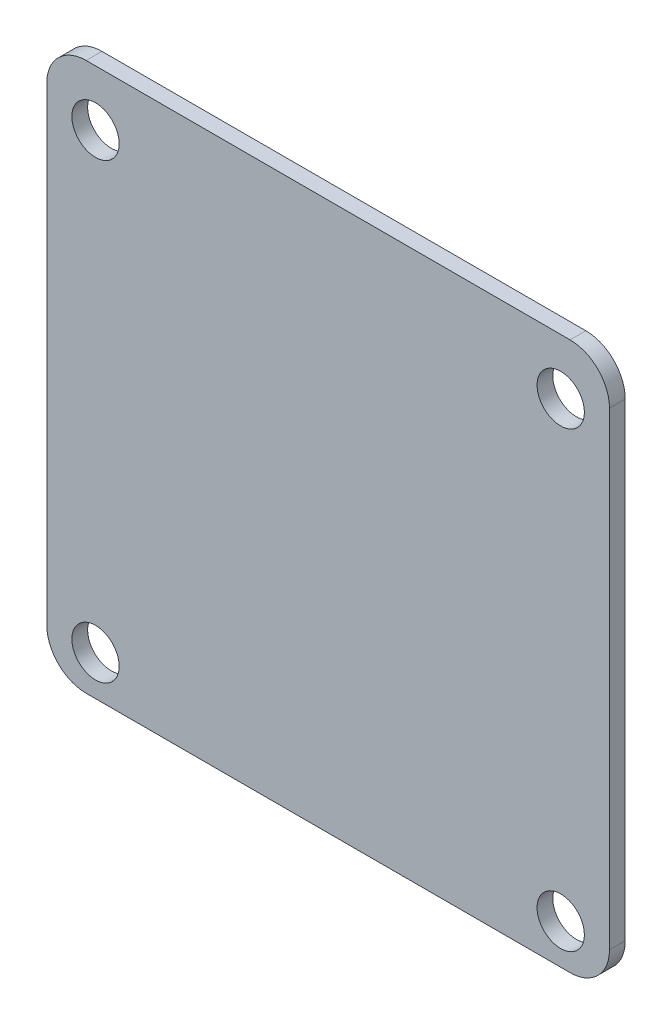
from build123d import *

# Parameters (mm, degrees)
ESQUISSE1_R        = 1.5
BOSS_EXTRU_1_DEPTH = 1


with BuildPart() as part:
    # Esquisse1 → Boss.-Extru.1 (new body)
    with BuildSketch(Plane.XY):
        with BuildLine():
            Line((113.101319879, -62.024555833), (143.787129504, -62.024555833))
            ThreePointArc((143.787129504, -62.024555833), (145.554896457, -62.75678888), (146.287129504, -64.524555833))
            Line((146.287129504, -64.524555833), (146.287129504, -94.278438772))
            ThreePointArc((146.287129504, -94.278438772), (145.554896457, -96.046205725), (143.787129504, -96.778438772))
            Line((143.787129504, -96.778438772), (113.101319879, -96.778438772))
            ThreePointArc((113.101319879, -96.778438772), (111.333552926, -96.046205725), (110.601319879, -94.278438772))
            Line((110.601319879, -94.278438772), (110.601319879, -64.524555833))
            ThreePointArc((110.601319879, -64.524555833), (111.333552926, -62.75678888), (113.101319879, -62.024555833))
        make_face()
        with Locations((143.194224692, -65.551497302)):
            Circle(ESQUISSE1_R, mode=Mode.SUBTRACT)
        with Locations((113.694224692, -65.551497302)):
            Circle(ESQUISSE1_R, mode=Mode.SUBTRACT)
        with Locations((113.694224692, -94.251497302)):
            Circle(ESQUISSE1_R, mode=Mode.SUBTRACT)
        with Locations((143.194224692, -94.251497302)):
            Circle(ESQUISSE1_R, mode=Mode.SUBTRACT)
    extrude(amount=BOSS_EXTRU_1_DEPTH)


solid = part.part
